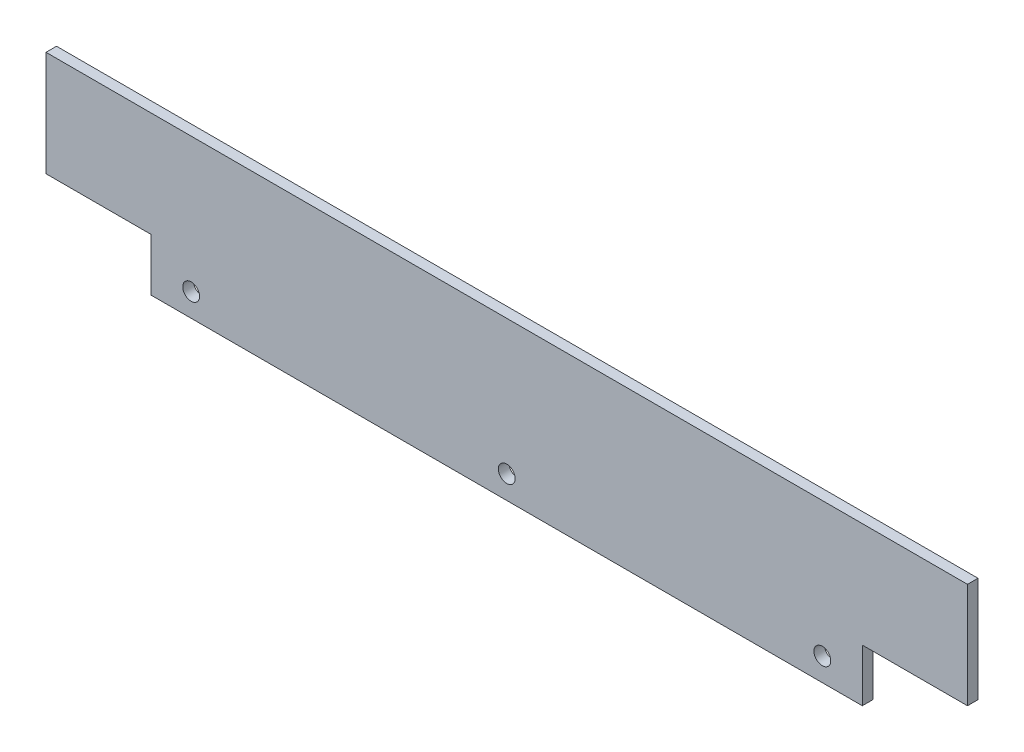
from build123d import *

# Parameters (mm, degrees)
CROQUIS1_R              = 4
SALIENTE_EXTRUIR1_DEPTH = 5


with BuildPart() as part:
    # Croquis1 → Saliente-Extruir1 (new body)
    with BuildSketch(Plane.XY):
        Polygon((0, 0), (-338, 0), (-338, 25), (-388, 25), (-388, 75), (50, 75), (50, 25), (0, 25), align=None)
        with Locations((-319, 11)):
            Circle(CROQUIS1_R, mode=Mode.SUBTRACT)
        with Locations((-19, 11)):
            Circle(CROQUIS1_R, mode=Mode.SUBTRACT)
        with Locations((-169, 11)):
            Circle(CROQUIS1_R, mode=Mode.SUBTRACT)
    extrude(amount=SALIENTE_EXTRUIR1_DEPTH)


solid = part.part
